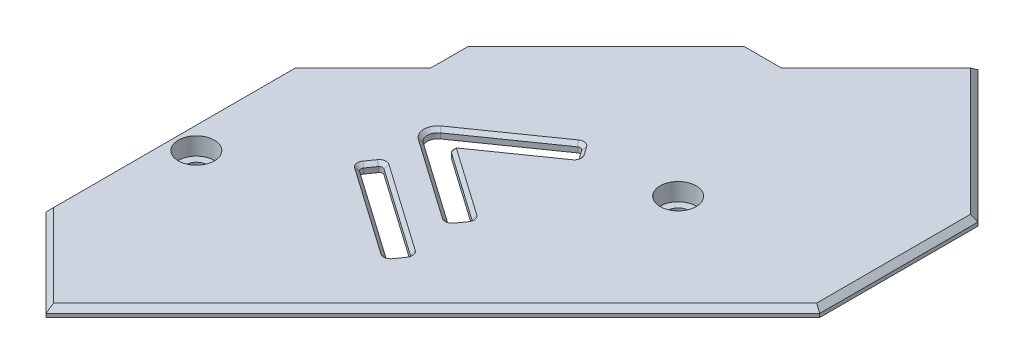
from build123d import *

# Parameters (mm, degrees)
EXTRUDE_1_DEPTH     = 1
CHAMFER_1_SIZE      = 0.6
SKETCH_2_W          = 6
SKETCH_2_H          = 6
EXTRUDE_2_DEPTH     = 3
SKETCH_3_R          = 1.2
CUT_EXTRUDE_1_DEPTH = 5
SKETCH_4_R          = 2.05
CUT_EXTRUDE_2_DEPTH = 2
FILLET_1_R          = 2
CUT_EXTRUDE_3_DEPTH = 5
FILLET_2_R          = 0.4
FILLET_3_R          = 1.2
CHAMFER_2_SIZE      = 0.4


with BuildPart() as part:
    # 草图1 → 凸台-拉伸1 (new body)
    with BuildSketch(Plane(origin=(0, 0, 0), x_dir=(1, 0, 0), z_dir=(0, 1, 0))):
        Polygon((0, 0), (44, 44), (44, 62), (29, 77), (18, 66), (13.757359313, 66), (-2.3, 49.942640687), (-2.3, 45.7), (-10, 38), (-10, 10), align=None)
    extrude(amount=EXTRUDE_1_DEPTH)

    # 倒角1
    chamfer_1_edges = [part.edges().sort_by_distance(p)[0] for p in [
        (44, 1, -53),
        (36.5, 1, -69.5),
        (23.5, 1, -71.5),
        (15.878679656, 1, -66),
        (5.728679656, 1, -57.971320344),
        (-2.3, 1, -47.821320344),
        (-6.15, 1, -41.85),
        (-10, 1, -24),
        (-5, 1, -5),
        (22, 1, -22),
    ]]
    chamfer(chamfer_1_edges, length=CHAMFER_1_SIZE)

    # 草图2 → 凸台-拉伸2 (add)
    with BuildSketch(Plane.XZ):
        with Locations((-7, -24)):
            Rectangle(SKETCH_2_W, SKETCH_2_H)
        with Locations((25, -47)):
            Rectangle(SKETCH_2_W, SKETCH_2_H)
    extrude(amount=EXTRUDE_2_DEPTH)

    # 草图3 → 切除-拉伸1 (cut, through all)
    with BuildSketch(Plane(origin=(0, -3, 0), x_dir=(-1, 0, 0), z_dir=(0, -1, 0))):
        with Locations((6.9, 24)):
            Circle(SKETCH_3_R)
        with Locations((-25, 46.9)):
            Circle(SKETCH_3_R)
    extrude(amount=-CUT_EXTRUDE_1_DEPTH, mode=Mode.SUBTRACT)

    # 草图4 → 切除-拉伸2 (cut)
    with BuildSketch(Plane(origin=(0, 1, 0), x_dir=(1, 0, 0), z_dir=(0, 1, 0))):
        with Locations((-6.9, 24)):
            Circle(SKETCH_4_R)
        with Locations((25, 46.9)):
            Circle(SKETCH_4_R)
    extrude(amount=-CUT_EXTRUDE_2_DEPTH, mode=Mode.SUBTRACT)

    # 圆角1
    fillet_1_edges = [part.edges().sort_by_distance(p)[0] for p in [
        (-4, -1.5, -27),
        (-4, -1.5, -21),
        (22, -1.5, -44),
        (22, -1.5, -50),
        (28, -1.5, -50),
        (28, -1.5, -44),
    ]]
    fillet(fillet_1_edges, radius=FILLET_1_R)

    # 草图5 → 切除-拉伸3 (cut, through all)
    with BuildSketch(Plane(origin=(0, 1, 0), x_dir=(1, 0, 0), z_dir=(0, 1, 0))):
        Polygon((14.352847127, 24.4), (15.5, 26.038304089), (4.851023424, 33.494797761), (3.703870552, 31.856493673), align=None)
        Polygon((14.352847127, 31.4), (3.444218368, 39.038304089), (14.352847127, 46.676608177), (15.5, 45.038304089), (6.93111196, 39.038304089), (15.5, 33.038304089), align=None)
    extrude(amount=-CUT_EXTRUDE_3_DEPTH, mode=Mode.SUBTRACT)

    # 圆角2
    fillet_2_edges = [part.edges().sort_by_distance(p)[0] for p in [
        (14.352847127, 0.5, -24.4),
        (3.703870552, 0.5, -31.856493673),
        (4.851023424, 0.5, -33.494797761),
        (15.5, 0.5, -26.038304089),
        (15.5, 0.5, -33.038304089),
        (14.352847127, 0.5, -31.4),
        (14.352847127, 0.5, -46.676608177),
        (15.5, 0.5, -45.038304089),
        (6.93111196, 0.5, -39.038304089),
    ]]
    fillet(fillet_2_edges, radius=FILLET_2_R)

    # 圆角3
    fillet_3_edges = [part.edges().sort_by_distance(p)[0] for p in [
        (3.444218368, 0.5, -39.038304089),
    ]]
    fillet(fillet_3_edges, radius=FILLET_3_R)

    # 倒角2
    chamfer_2_edges = [part.edges().sort_by_distance(p)[0] for p in [
        (11.285699643, 1, -42.08741921),
        (9.028358839, 1, -28.128246836),
        (4.277446988, 1, -32.675645717),
        (10.175511712, 1, -29.766550925),
        (14.926423564, 1, -25.219152044),
        (14.926423564, 1, -32.219152044),
        (9.436624555, 1, -43.234232072),
        (14.926423564, 1, -45.857456133),
        (11.285699643, 1, -35.989188967),
        (7.228490678, 1, -39.038304089),
        (14.324076155, 1, -46.513439886),
        (15.336831709, 1, -45.067075061),
        (15.336831709, 1, -33.009533116),
        (14.324076155, 1, -31.563168291),
        (15.336831709, 1, -26.009533116),
        (14.324076155, 1, -24.563168291),
        (4.879794396, 1, -33.33162947),
        (3.867038843, 1, -31.885264645),
        (9.436624555, 1, -34.842376105),
        (4.336354523, 1, -39.038304089),
    ]]
    chamfer(chamfer_2_edges, length=CHAMFER_2_SIZE)


solid = part.part
